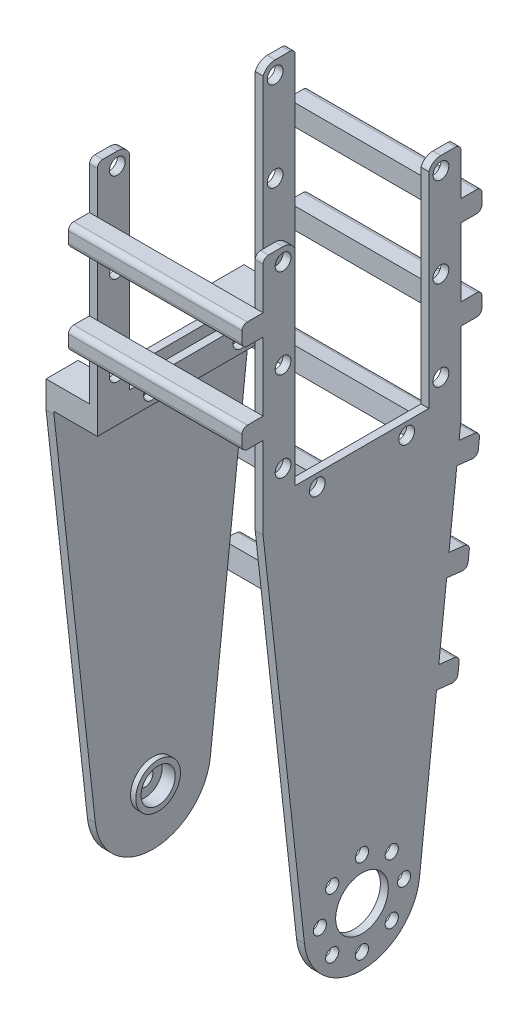
from build123d import *

# Parameters (mm, degrees)
SKETCH4_R            = 1.5
SKETCH4_W            = 25.4
SKETCH4_H            = 4.6
SKETCH4_W_2          = 6.1
SKETCH4_W_3          = 4
SKETCH4_H_2          = 4
BOSS_EXTRUDE1_DEPTH  = 1.5
SKETCH4_4_W          = 6.1
SKETCH4_4_H          = 4.6
BOSS_EXTRUDE3_DEPTH  = 6.75
BOSS_EXTRUDE4_START  = -6.75
SKETCH4_5_R          = 3.25
BOSS_EXTRUDE4_DEPTH  = 1.5
BOSS_EXTRUDE5_START  = -6.75
SKETCH4_7_R          = 4.25
SKETCH4_7_R_2        = 3.25
BOSS_EXTRUDE5_DEPTH  = 1
SKETCH5_R            = 5.25
SKETCH5_R_2          = 1.5
BOSS_EXTRUDE6_DEPTH  = 1
BOSS_EXTRUDE7_START  = 31.5
SKETCH4_9_R          = 1.25
SKETCH4_9_R_2        = 5
SKETCH4_9_R_3        = 1.5
SKETCH4_9_W          = 6.1
SKETCH4_9_H          = 4.6
SKETCH4_9_W_2        = 25.4
SKETCH4_9_W_3        = 4
SKETCH4_9_H_2        = 4
BOSS_EXTRUDE7_DEPTH  = 1.5
BOSS_EXTRUDE8_START  = 1.5
SKETCH4_11_W         = 4
SKETCH4_11_H         = 4
BOSS_EXTRUDE8_DEPTH  = 30
BOSS_EXTRUDE9_START  = -8.25
BOSS_EXTRUDE9_DEPTH  = 41.25
FILLET1_R            = 1
BOSS_EXTRUDE10_REACH = 127.173
FILLET3_R            = 1


with BuildPart() as part:
    # Sketch4 → Boss-Extrude1 (new body)
    with BuildSketch(Plane(origin=(0, 0, 0), x_dir=(0, 0, -1), z_dir=(1, 0, 0))):
        with BuildLine():
            Line((12.7, 113.1), (12.7, 75.1))
            Line((12.7, 75.1), (18.8, 75.1))
            Line((18.8, 75.1), (18.8, 85.6))
            Line((18.8, 85.6), (18.8, 89.6))
            Line((18.8, 89.6), (18.8, 102.6))
            Line((18.8, 102.6), (18.8, 106.6))
            Line((18.8, 106.6), (18.8, 115.6))
            Line((18.8, 115.6), (15, 115.6))
            ThreePointArc((15, 115.6), (13.621502583, 115.185604198), (12.7, 114.079795897))
            Line((12.7, 114.079795897), (12.7, 113.1))
        make_face()
        with Locations((15, 79.1)):
            Circle(SKETCH4_R, mode=Mode.SUBTRACT)
        with Locations((15, 96.1)):
            Circle(SKETCH4_R, mode=Mode.SUBTRACT)
        with Locations((15, 113.1)):
            Circle(SKETCH4_R, mode=Mode.SUBTRACT)
        with Locations((0, 72.8)):
            Rectangle(SKETCH4_W, SKETCH4_H)
        with Locations((-8.5, 72.8)):
            Circle(SKETCH4_R, mode=Mode.SUBTRACT)
        with Locations((8.5, 72.8)):
            Circle(SKETCH4_R, mode=Mode.SUBTRACT)
        with BuildLine():
            Line((-18.8, 75.1), (-12.7, 75.1))
            Line((-12.7, 75.1), (-12.7, 113.1))
            Line((-12.7, 113.1), (-12.7, 114.079795897))
            ThreePointArc((-12.7, 114.079795897), (-13.621502583, 115.185604198), (-15, 115.6))
            Line((-15, 115.6), (-18.8, 115.6))
            Line((-18.8, 115.6), (-18.8, 106.6))
            Line((-18.8, 106.6), (-18.8, 102.6))
            Line((-18.8, 102.6), (-18.8, 89.6))
            Line((-18.8, 89.6), (-18.8, 85.6))
            Line((-18.8, 85.6), (-18.8, 75.1))
        make_face()
        with Locations((-15, 79.1)):
            Circle(SKETCH4_R, mode=Mode.SUBTRACT)
        with Locations((-15, 96.1)):
            Circle(SKETCH4_R, mode=Mode.SUBTRACT)
        with Locations((-15, 113.1)):
            Circle(SKETCH4_R, mode=Mode.SUBTRACT)
        with Locations((15.75, 72.8)):
            Rectangle(SKETCH4_W_2, SKETCH4_H)
        with Locations((-15.75, 72.8)):
            Rectangle(SKETCH4_W_2, SKETCH4_H)
        with Locations((-20.8, 87.6)):
            Rectangle(SKETCH4_W_3, SKETCH4_H_2)
        with Locations((-20.8, 104.6)):
            Rectangle(SKETCH4_W_3, SKETCH4_H_2)
        with Locations((20.8, 104.6)):
            Rectangle(SKETCH4_W_3, SKETCH4_H_2)
        with Locations((20.8, 87.6)):
            Rectangle(SKETCH4_W_3, SKETCH4_H_2)
    extrude(amount=BOSS_EXTRUDE1_DEPTH)

    # Sketch4_4 → Boss-Extrude3 (add)
    with BuildSketch(Plane(origin=(0, 0, 0), x_dir=(0, 0, -1), z_dir=(1, 0, 0))):
        with Locations((15.75, 72.8)):
            Rectangle(SKETCH4_4_W, SKETCH4_4_H)
        with Locations((-15.75, 72.8)):
            Rectangle(SKETCH4_4_W, SKETCH4_4_H)
    extrude(amount=-BOSS_EXTRUDE3_DEPTH)

    # Sketch4_5 → Boss-Extrude4 (add)
    with BuildSketch(Plane(origin=(0, 0, 0), x_dir=(0, 0, -1), z_dir=(1, 0, 0)).offset(BOSS_EXTRUDE4_START)):
        with BuildLine():
            Line((-12.7, 70.5), (-12.7, 75.1))
            Line((-12.7, 75.1), (-18.8, 75.1))
            Line((-18.8, 75.1), (-18.8, 70))
            Line((-18.8, 70), (-10.933485156, -1.207850299))
            ThreePointArc((-10.933485156, -1.207850299), (0, -11), (10.933485156, -1.207850299))
            Line((10.933485156, -1.207850299), (18.8, 70))
            Line((18.8, 70), (18.8, 75.1))
            Line((18.8, 75.1), (12.7, 75.1))
            Line((12.7, 75.1), (12.7, 70.5))
            Line((12.7, 70.5), (-12.7, 70.5))
        make_face()
        Circle(SKETCH4_5_R, mode=Mode.SUBTRACT)
    extrude(amount=-BOSS_EXTRUDE4_DEPTH)

    # Sketch4_7 → Boss-Extrude5 (add)
    with BuildSketch(Plane(origin=(0, 0, 0), x_dir=(0, 0, -1), z_dir=(1, 0, 0)).offset(BOSS_EXTRUDE5_START)):
        Circle(SKETCH4_7_R)
        Circle(SKETCH4_7_R_2, mode=Mode.SUBTRACT)
    extrude(amount=BOSS_EXTRUDE5_DEPTH)

    # Sketch5 → Boss-Extrude6 (add)
    with BuildSketch(Plane.ZY.offset(8.25)):
        with Locations(Location((0, 0, 0), (0, 0, 180))):
            Circle(SKETCH5_R)
        Circle(SKETCH5_R_2, mode=Mode.SUBTRACT)
    extrude(amount=BOSS_EXTRUDE6_DEPTH)



with BuildPart() as body_2:
    # Sketch4_9 → Boss-Extrude7 (new body)
    with BuildSketch(Plane(origin=(0, 0, 0), x_dir=(0, 0, -1), z_dir=(1, 0, 0)).offset(BOSS_EXTRUDE7_START)):
        with BuildLine():
            Line((12.7, 70.5), (-12.7, 70.5))
            Line((-12.7, 70.5), (-18.8, 70.5))
            Line((-18.8, 70.5), (-18.8, 70))
            Line((-18.8, 70), (-18.467246252, 66.987906392))
            Line((-18.467246252, 66.987906392), (-18.028027961, 63.012093608))
            Line((-18.028027961, 63.012093608), (-14.600705998, 31.987906392))
            Line((-14.600705998, 31.987906392), (-14.161487708, 28.012093608))
            Line((-14.161487708, 28.012093608), (-10.933485156, -1.207850299))
            ThreePointArc((-10.933485156, -1.207850299), (0, -11), (10.933485156, -1.207850299))
            Line((10.933485156, -1.207850299), (14.161487708, 28.012093608))
            Line((14.161487708, 28.012093608), (14.600705998, 31.987906392))
            Line((14.600705998, 31.987906392), (18.028027961, 63.012093608))
            Line((18.028027961, 63.012093608), (18.467246252, 66.987906392))
            Line((18.467246252, 66.987906392), (18.8, 70))
            Line((18.8, 70), (18.8, 70.5))
            Line((18.8, 70.5), (12.7, 70.5))
        make_face()
        with Locations((-8, 0)):
            Circle(SKETCH4_9_R, mode=Mode.SUBTRACT)
        with Locations((-5.656854249, -5.656854249)):
            Circle(SKETCH4_9_R, mode=Mode.SUBTRACT)
        Circle(SKETCH4_9_R_2, mode=Mode.SUBTRACT)
        with Locations((-5.656854249, 5.656854249)):
            Circle(SKETCH4_9_R, mode=Mode.SUBTRACT)
        with Locations((0, 8)):
            Circle(SKETCH4_9_R, mode=Mode.SUBTRACT)
        with Locations((0, -8)):
            Circle(SKETCH4_9_R, mode=Mode.SUBTRACT)
        with Locations((5.656854249, -5.656854249)):
            Circle(SKETCH4_9_R, mode=Mode.SUBTRACT)
        with Locations((8, 0)):
            Circle(SKETCH4_9_R, mode=Mode.SUBTRACT)
        with Locations((5.656854249, 5.656854249)):
            Circle(SKETCH4_9_R, mode=Mode.SUBTRACT)
        with BuildLine():
            Line((-18.8, 75.1), (-12.7, 75.1))
            Line((-12.7, 75.1), (-12.7, 113.1))
            Line((-12.7, 113.1), (-12.7, 114.079795897))
            ThreePointArc((-12.7, 114.079795897), (-13.621502583, 115.185604198), (-15, 115.6))
            Line((-15, 115.6), (-18.8, 115.6))
            Line((-18.8, 115.6), (-18.8, 106.6))
            Line((-18.8, 106.6), (-18.8, 102.6))
            Line((-18.8, 102.6), (-18.8, 89.6))
            Line((-18.8, 89.6), (-18.8, 85.6))
            Line((-18.8, 85.6), (-18.8, 75.1))
        make_face()
        with Locations((-15, 79.1)):
            Circle(SKETCH4_9_R_3, mode=Mode.SUBTRACT)
        with Locations((-15, 96.1)):
            Circle(SKETCH4_9_R_3, mode=Mode.SUBTRACT)
        with Locations((-15, 113.1)):
            Circle(SKETCH4_9_R_3, mode=Mode.SUBTRACT)
        with Locations((-15.75, 72.8)):
            Rectangle(SKETCH4_9_W, SKETCH4_9_H)
        with Locations((15.75, 72.8)):
            Rectangle(SKETCH4_9_W, SKETCH4_9_H)
        with Locations((0, 72.8)):
            Rectangle(SKETCH4_9_W_2, SKETCH4_9_H)
        with Locations((-8.5, 72.8)):
            Circle(SKETCH4_9_R_3, mode=Mode.SUBTRACT)
        with Locations((8.5, 72.8)):
            Circle(SKETCH4_9_R_3, mode=Mode.SUBTRACT)
        with BuildLine():
            Line((12.7, 113.1), (12.7, 75.1))
            Line((12.7, 75.1), (18.8, 75.1))
            Line((18.8, 75.1), (18.8, 85.6))
            Line((18.8, 85.6), (18.8, 89.6))
            Line((18.8, 89.6), (18.8, 102.6))
            Line((18.8, 102.6), (18.8, 106.6))
            Line((18.8, 106.6), (18.8, 115.6))
            Line((18.8, 115.6), (15, 115.6))
            ThreePointArc((15, 115.6), (13.621502583, 115.185604198), (12.7, 114.079795897))
            Line((12.7, 114.079795897), (12.7, 113.1))
        make_face()
        with Locations((15, 79.1)):
            Circle(SKETCH4_9_R_3, mode=Mode.SUBTRACT)
        with Locations((15, 96.1)):
            Circle(SKETCH4_9_R_3, mode=Mode.SUBTRACT)
        with Locations((15, 113.1)):
            Circle(SKETCH4_9_R_3, mode=Mode.SUBTRACT)
        with Locations((-20.8, 104.6)):
            Rectangle(SKETCH4_9_W_3, SKETCH4_9_H_2)
        with Locations((-20.8, 87.6)):
            Rectangle(SKETCH4_9_W_3, SKETCH4_9_H_2)
        with Locations((20.8, 104.6)):
            Rectangle(SKETCH4_9_W_3, SKETCH4_9_H_2)
        with Locations((20.8, 87.6)):
            Rectangle(SKETCH4_9_W_3, SKETCH4_9_H_2)
    extrude(amount=BOSS_EXTRUDE7_DEPTH)


with BuildPart() as part_1:
    add(part.part)

    add(body_2.part)  # Boss-Extrude8 merges body 2
    # Sketch4_11 → Boss-Extrude8 (add)
    with BuildSketch(Plane(origin=(0, 0, 0), x_dir=(0, 0, -1), z_dir=(1, 0, 0)).offset(BOSS_EXTRUDE8_START)):
        with Locations((-20.8, 87.6)):
            Rectangle(SKETCH4_11_W, SKETCH4_11_H)
        with Locations((-20.8, 104.6)):
            Rectangle(SKETCH4_11_W, SKETCH4_11_H)
        with Locations((20.8, 104.6)):
            Rectangle(SKETCH4_11_W, SKETCH4_11_H)
        with Locations((20.8, 87.6)):
            Rectangle(SKETCH4_11_W, SKETCH4_11_H)
    extrude(amount=BOSS_EXTRUDE8_DEPTH)

    # Sketch4_12 → Boss-Extrude9 (add)
    with BuildSketch(Plane(origin=(0, 0, 0), x_dir=(0, 0, -1), z_dir=(1, 0, 0)).offset(BOSS_EXTRUDE9_START)):
        Polygon((22.443059036, 66.548688101), (18.467246252, 66.987906392), (18.028027961, 63.012093608), (22.003840745, 62.572875317), align=None)
        Polygon((18.576518782, 31.548688101), (14.600705998, 31.987906392), (14.161487708, 28.012093608), (18.137300492, 27.572875317), align=None)
    extrude(amount=BOSS_EXTRUDE9_DEPTH)

    # Fillet1
    fillet1_edges = [part_1.edges().sort_by_distance(p)[0] for p in [
        (32.25, 115.6, 18.8),
        (32.25, 115.6, -18.8),
        (0.75, 115.6, -18.8),
        (0.75, 115.6, 18.8),
        (16.5, 89.6, 22.8),
        (16.5, 85.6, 22.8),
        (16.5, 106.6, 22.8),
        (16.5, 102.6, 22.8),
        (16.5, 102.6, -22.8),
        (16.5, 106.6, -22.8),
        (16.5, 85.6, -22.8),
        (16.5, 89.6, -22.8),
    ]]
    fillet(fillet1_edges, radius=FILLET1_R)

    # Boss-Extrude10: up to this face of the body (flat: up to its plane)
    boss_extrude10_end = Plane(part_1.part.faces().sort_by_distance((-8.25, 37.164780502, -0.254514777))[0])
    # Sketch6 → Boss-Extrude10 (add, up to the picked face)
    with BuildSketch(Plane(origin=(33, 0, 0), x_dir=(0, 0, -1), z_dir=(1, 0, 0)), mode=Mode.PRIVATE) as boss_extrude10_sk1:
        Polygon((16.094757835, 45.512093608), (16.533976125, 49.487906392), (20.509788909, 49.048688101), (20.070570619, 45.072875318), align=None)
    boss_extrude10_tool1 = split(extrude(boss_extrude10_sk1.sketch, amount=-BOSS_EXTRUDE10_REACH, mode=Mode.PRIVATE), bisect_by=boss_extrude10_end, keep=Keep.BOTH, mode=Mode.PRIVATE)
    add(boss_extrude10_tool1.solids().sort_by(Axis((33, 47.280391, -18.302273), (-1, 0, 0)))[0])

    # Fillet3
    fillet3_edges = [part_1.edges().sort_by_distance(p)[0] for p in [
        (12.375, 66.548688101, -22.443059036),
        (12.375, 62.572875317, -22.003840745),
        (12.375, 31.548688101, -18.576518782),
        (12.375, 27.572875317, -18.137300492),
        (12.375, 45.072875318, -20.070570619),
        (12.375, 49.048688101, -20.509788909),
    ]]
    fillet(fillet3_edges, radius=FILLET3_R)


solid = part_1.part
